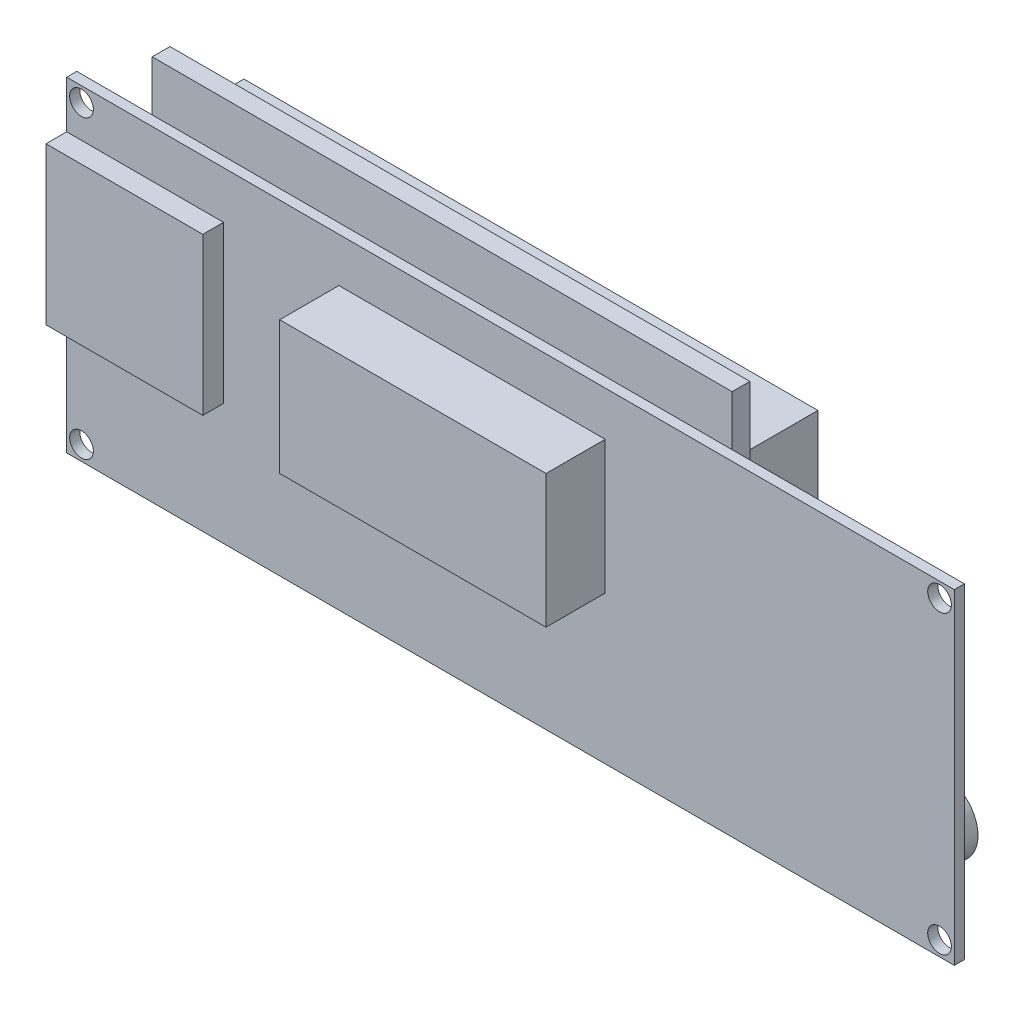
from build123d import *

# Parameters (mm, degrees)
SKETCH2_R           = 2
BOSS_EXTRUDE1_DEPTH = 1.7
SKETCH3_W           = 98
SKETCH3_H           = 60
BOSS_EXTRUDE2_DEPTH = 3
SKETCH4_W           = 97
SKETCH4_H           = 40
BOSS_EXTRUDE3_DEPTH = 15
SKETCH5_W           = 6
SKETCH5_H           = 6
BOSS_EXTRUDE4_DEPTH = 3
SKETCH6_R           = 1.75
BOSS_EXTRUDE5_DEPTH = 0.65
SKETCH7_W           = 12.25
SKETCH7_H           = 11.75
BOSS_EXTRUDE6_DEPTH = 4.5
SKETCH8_R           = 6
BOSS_EXTRUDE7_DEPTH = 9.3
SKETCH9_W           = 45
SKETCH9_H           = 22.5
BOSS_EXTRUDE8_DEPTH = 10
SKETCH10_W          = 26.5
SKETCH10_H          = 26.5
BOSS_EXTRUDE9_DEPTH = 3.5
SKETCH11_W          = 76
SKETCH11_H          = 26
CUT_EXTRUDE1_DEPTH  = 0.5


with BuildPart() as part:
    # Sketch2 → Boss-Extrude1 (new body)
    with BuildSketch(Plane.XY):
        Polygon((75, 27.5), (75, -27.5), (-75, -27.5), (-75, 27.5), (-62.25, 27.5), (35.75, 27.5), align=None)
        with Locations((-72.5, -25)):
            Circle(SKETCH2_R, mode=Mode.SUBTRACT)
        with Locations((-72.5, 25)):
            Circle(SKETCH2_R, mode=Mode.SUBTRACT)
        with Locations((72.5, -25)):
            Circle(SKETCH2_R, mode=Mode.SUBTRACT)
        with Locations((72.5, 25)):
            Circle(SKETCH2_R, mode=Mode.SUBTRACT)
    extrude(amount=BOSS_EXTRUDE1_DEPTH)

    # Sketch3 → Boss-Extrude2 (add)
    with BuildSketch(Plane.XY):
        with Locations((-13.25, 6)):
            Rectangle(SKETCH3_W, SKETCH3_H)
    extrude(amount=-BOSS_EXTRUDE2_DEPTH)

    # Sketch4 → Boss-Extrude3 (add)
    with BuildSketch(Plane.XY):
        with Locations((-13.25, 5.5)):
            Rectangle(SKETCH4_W, SKETCH4_H)
    extrude(amount=-BOSS_EXTRUDE3_DEPTH)

    # Sketch5 → Boss-Extrude4 (add)
    with BuildSketch(Plane.XY):
        with Locations((62, 20)):
            Rectangle(SKETCH5_W, SKETCH5_H)
    extrude(amount=-BOSS_EXTRUDE4_DEPTH)

    # Sketch6 → Boss-Extrude5 (add)
    with BuildSketch(Plane(origin=(0, 0, -3), x_dir=(-1, 0, 0), z_dir=(0, 0, -1))):
        with Locations((-62, 20)):
            Circle(SKETCH6_R)
    extrude(amount=BOSS_EXTRUDE5_DEPTH)

    # Sketch7 → Boss-Extrude6 (add)
    with BuildSketch(Plane.XY):
        with Locations((62, 2.5)):
            Rectangle(SKETCH7_W, SKETCH7_H)
    extrude(amount=-BOSS_EXTRUDE6_DEPTH)

    # Sketch8 → Boss-Extrude7 (add)
    with BuildSketch(Plane.XY):
        with Locations((62, -17.5)):
            Circle(SKETCH8_R)
    extrude(amount=-BOSS_EXTRUDE7_DEPTH)

    # Sketch9 → Boss-Extrude8 (add)
    with BuildSketch(Plane.XY.offset(1.7)):
        with Locations((-6.5, 8.75)):
            Rectangle(SKETCH9_W, SKETCH9_H)
    extrude(amount=BOSS_EXTRUDE8_DEPTH)

    # Sketch10 → Boss-Extrude9 (add)
    with BuildSketch(Plane.XY.offset(1.7)):
        with Locations((-61.75, 6.25)):
            Rectangle(SKETCH10_W, SKETCH10_H)
    extrude(amount=BOSS_EXTRUDE9_DEPTH)

    # Sketch11 → Cut-Extrude1 (cut)
    with BuildSketch(Plane(origin=(0, 0, -15), x_dir=(-1, 0, 0), z_dir=(0, 0, -1))):
        with Locations((13.25, 5.5)):
            Rectangle(SKETCH11_W, SKETCH11_H)
    extrude(amount=-CUT_EXTRUDE1_DEPTH, mode=Mode.SUBTRACT)


solid = part.part
